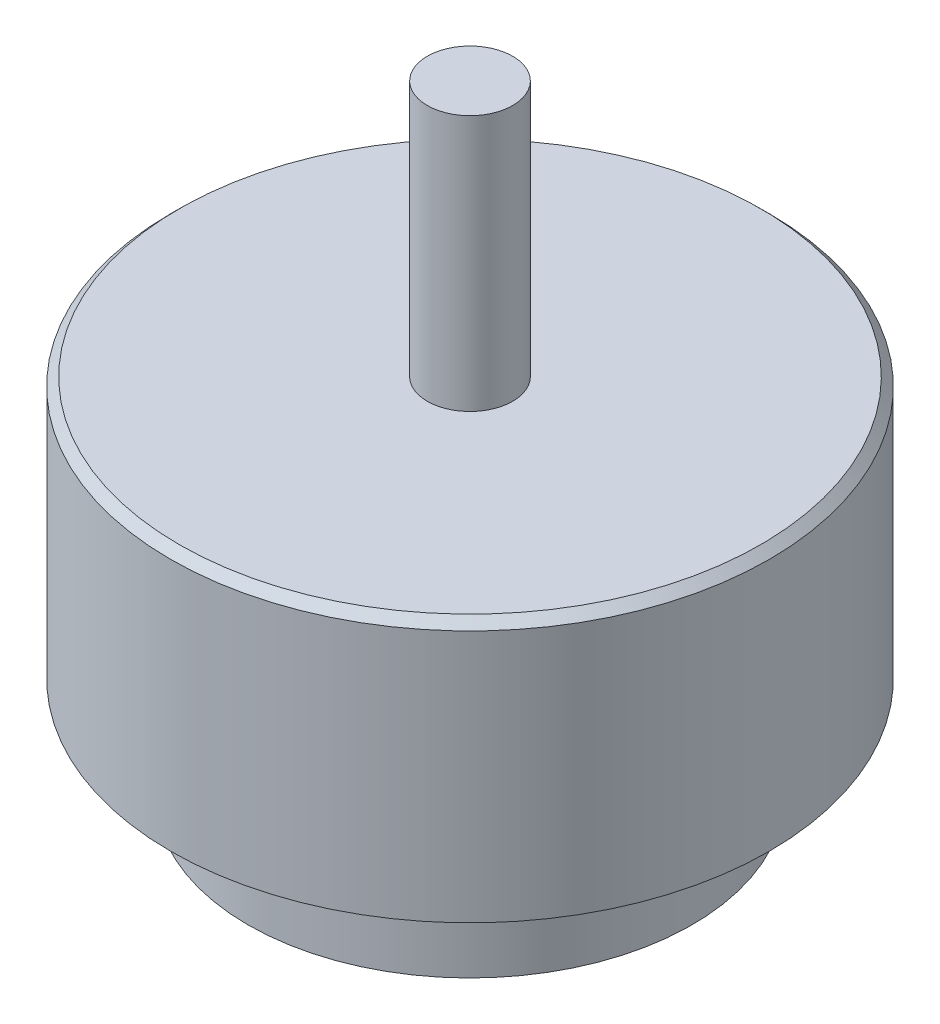
from build123d import *

# Parameters (mm, degrees)
SKETCH1_R           = 13
BOSS_EXTRUDE1_DEPTH = 6
SKETCH2_R           = 17.53
BOSS_EXTRUDE2_DEPTH = 15.3
SKETCH3_R           = 2.5
BOSS_EXTRUDE3_DEPTH = 15
CHAMFER1_SIZE       = 0.5
SKETCH4_R           = 7
CUT_EXTRUDE1_DEPTH  = 6


with BuildPart() as part:
    # Sketch1 → Boss-Extrude1 (new body)
    with BuildSketch(Plane(origin=(0, 0, 0), x_dir=(1, 0, 0), z_dir=(0, 1, 0))):
        Circle(SKETCH1_R)
    extrude(amount=BOSS_EXTRUDE1_DEPTH)

    # Sketch2 → Boss-Extrude2 (add)
    with BuildSketch(Plane(origin=(0, 6, 0), x_dir=(1, 0, 0), z_dir=(0, 1, 0))):
        Circle(SKETCH2_R)
    extrude(amount=BOSS_EXTRUDE2_DEPTH)

    # Sketch3 → Boss-Extrude3 (add)
    with BuildSketch(Plane(origin=(0, 21.3, 0), x_dir=(1, 0, 0), z_dir=(0, 1, 0))):
        Circle(SKETCH3_R)
    extrude(amount=BOSS_EXTRUDE3_DEPTH)

    # Chamfer1
    chamfer1_edges = [part.edges().sort_by_distance(p)[0] for p in [
        (-17.53, 21.3, 0),
    ]]
    chamfer(chamfer1_edges, length=CHAMFER1_SIZE)

    # Sketch4 → Cut-Extrude1 (cut)
    with BuildSketch(Plane.XZ):
        Circle(SKETCH4_R)
    extrude(amount=-CUT_EXTRUDE1_DEPTH, mode=Mode.SUBTRACT)


solid = part.part
